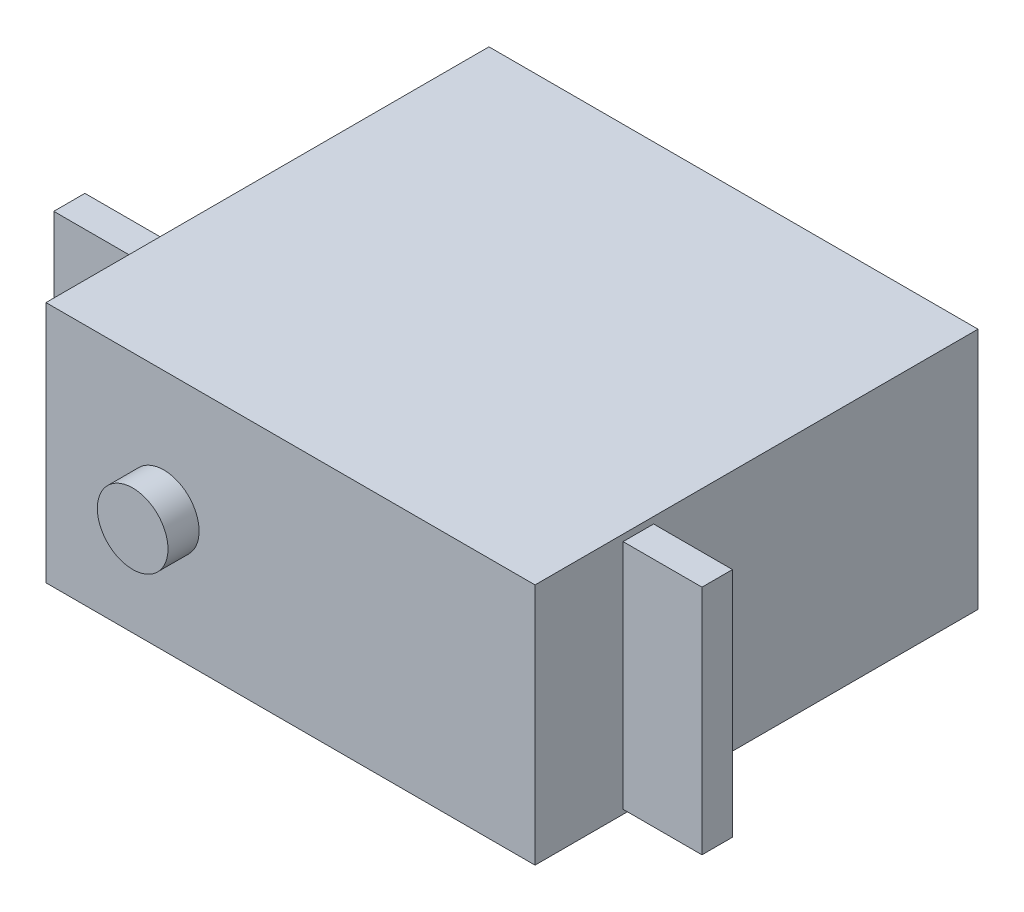
from build123d import *

# Parameters (mm, degrees)
SKETCH1_W           = 39.9161
SKETCH1_H           = 36.1569
BOSS_EXTRUDE1_DEPTH = 19.812
SKETCH2_W           = 2.4892
SKETCH2_H           = 18.923
BOSS_EXTRUDE3_DEPTH = 6.4389
SKETCH4_W           = 2.54
SKETCH4_H           = 18.923
BOSS_EXTRUDE4_DEPTH = 6.4389
SKETCH5_R           = 2.8829
BOSS_EXTRUDE5_DEPTH = 2.54


with BuildPart() as part:
    # Sketch1 → Boss-Extrude1 (new body)
    with BuildSketch(Plane(origin=(0, 0, 0), x_dir=(1, 0, 0), z_dir=(0, 1, 0))):
        with Locations((-19.95805, -18.07845)):
            Rectangle(SKETCH1_W, SKETCH1_H)
    extrude(amount=BOSS_EXTRUDE1_DEPTH)

    # Sketch2 → Boss-Extrude3 (add)
    with BuildSketch(Plane(origin=(0, 0, 0), x_dir=(0, 0, -1), z_dir=(1, 0, 0))):
        with Locations((-27.7241, 9.8171)):
            Rectangle(SKETCH2_W, SKETCH2_H)
    extrude(amount=BOSS_EXTRUDE3_DEPTH)

    # Sketch4 → Boss-Extrude4 (add)
    with BuildSketch(Plane.ZY.offset(39.9161)):
        with Locations((27.813, 10.0457)):
            Rectangle(SKETCH4_W, SKETCH4_H)
    extrude(amount=BOSS_EXTRUDE4_DEPTH)

    # Sketch5 → Boss-Extrude5 (add)
    with BuildSketch(Plane.XY.offset(36.1569)):
        with Locations((-30.3022, 9.906)):
            Circle(SKETCH5_R)
    extrude(amount=BOSS_EXTRUDE5_DEPTH)


solid = part.part
